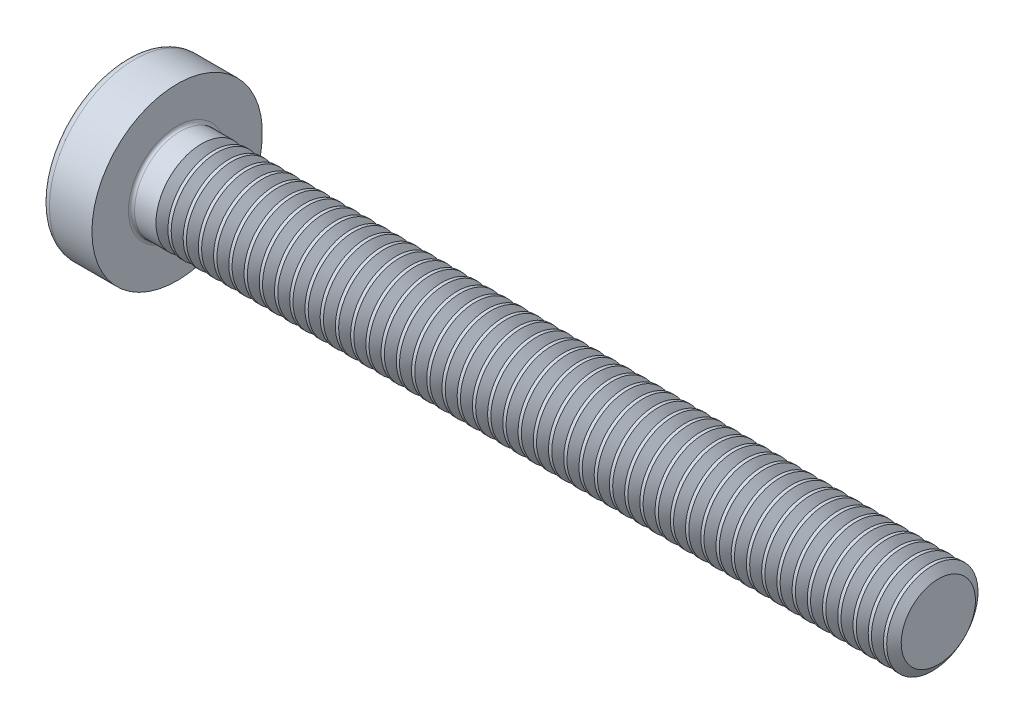
from build123d import *

# Parameters (mm, degrees)
FILLET1_R       = 0.1
SKETCH3_W       = 0.74
SKETCH3_H       = 2.8
SKETCH4_W       = 0.74
SKETCH4_H       = 1.054964664
RECPAT_COUNT    = 2
RECPAT_ANGLE    = 90
THDSCHPAT_COUNT = 49
THDSCHPAT_PITCH = 0.5


with BuildPart() as part:
    # BodySke → Base-Revolve (revolve)
    with BuildSketch(Plane.XY):
        with BuildLine():
            Line((2.4, 1.5), (2.4, 2.8))
            Line((2.4, 2.8), (1.003501533, 2.8))
            ThreePointArc((1.003501533, 2.8), (0.873295971, 2.76653015), (0.775371599, 2.674418605))
            ThreePointArc((0.775371599, 2.674418605), (0.197753546, 1.392274756), (0, 0))
            Line((0, 0), (27.4, 0))
            Line((27.4, 0), (27.4, 1.5))
            Line((27.4, 1.5), (2.4, 1.5))
        make_face()
    revolve(axis=Axis((-25.4, 0, 0), (1, 0, 0)))

    # Fillet1
    fillet1_edges = [part.edges().sort_by_distance(p)[0] for p in [
        (2.4, -1.5, 0),
    ]]
    fillet(fillet1_edges, radius=FILLET1_R)

    # Sketch3 → Recess section 0
    with BuildSketch(Plane(origin=(0, 0, 0), x_dir=(0, 0, -1), z_dir=(1, 0, 0))):
        Rectangle(SKETCH3_W, SKETCH3_H)
    # Sketch4 → Recess section 1
    with BuildSketch(Plane(origin=(1.75, 0, 0), x_dir=(0, 0, -1), z_dir=(1, 0, 0))):
        Rectangle(SKETCH4_W, SKETCH4_H)
    recess = loft(mode=Mode.SUBTRACT)

    # RecPat: Recess ×2 about axis
    recpat_axis = Axis((0, 0, 0), (1, 0, 0))
    for i in range(1, RECPAT_COUNT):
        add(recess.rotate(recpat_axis, i * RECPAT_ANGLE / (RECPAT_COUNT - 1)), mode=Mode.SUBTRACT)

    # RecCorSke → RecessCore (revolve, cut)
    with BuildSketch(Plane.XY):
        Polygon((0, 0), (0, 0.678371921), (1.75, 0.556), (1.930655351, 0), align=None)
    revolve(axis=Axis((-3.175, 0, 0), (1, 0, 0)), mode=Mode.SUBTRACT)

    # ThdSchSke → ThreadSchematic (revolve, cut)
    with BuildSketch(Plane.XY):
        Polygon((3.4, -1.2195), (3.203591786, -1.5), (3.203591786, -1.875), (3.596408214, -1.875), (3.596408214, -1.5), align=None)
    threadschematic = revolve(axis=Axis((-3.175, 0, 0), (1, 0, 0)), mode=Mode.SUBTRACT)

    # ThdSchPat: ThreadSchematic ×49
    with Locations(*[(i * THDSCHPAT_PITCH, 0, 0) for i in range(1, THDSCHPAT_COUNT)]):
        add(threadschematic, mode=Mode.SUBTRACT)


solid = part.part
